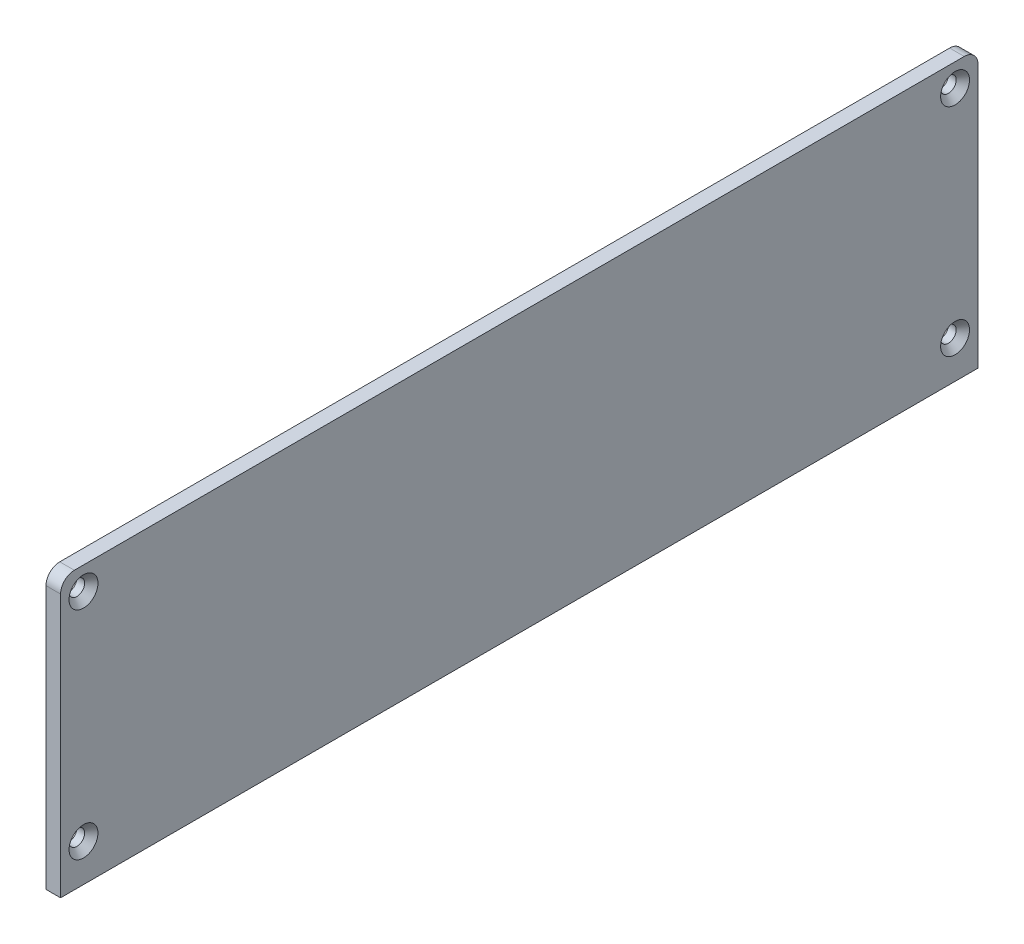
from build123d import *

# Parameters (mm, degrees)
BOSS_EXTRUDE1_DEPTH                             = 3.175
CSK_FOR_M3_FLAT_HEAD_MACHINE_SCREW1_D           = 3.4
CSK_FOR_M3_FLAT_HEAD_MACHINE_SCREW1_CSINK_D     = 6.3
CSK_FOR_M3_FLAT_HEAD_MACHINE_SCREW1_CSINK_ANGLE = 90


with BuildPart() as part:
    # Sketch1 → Boss-Extrude1 (new body)
    with BuildSketch(Plane(origin=(0, 0, 0), x_dir=(0, 0, -1), z_dir=(1, 0, 0))):
        with BuildLine():
            Line((-100, 0), (100, 0))
            Line((100, 0), (100, 57.35))
            ThreePointArc((100, 57.35), (99.121320344, 59.471320344), (97, 60.35))
            Line((97, 60.35), (-97, 60.35))
            ThreePointArc((-97, 60.35), (-99.121320344, 59.471320344), (-100, 57.35))
            Line((-100, 57.35), (-100, 0))
        make_face()
    extrude(amount=BOSS_EXTRUDE1_DEPTH)

    # CSK for M3 Flat Head Machine Screw1 (through all)
    with Locations(Plane(origin=(3.175, 0, 0), x_dir=(0, 0, -1), z_dir=(1, 0, 0))):
        with Locations((-95, 8.175), (-95, 55.35)):
            csk_for_m3_flat_head_machine_screw1 = CounterSinkHole(CSK_FOR_M3_FLAT_HEAD_MACHINE_SCREW1_D / 2, CSK_FOR_M3_FLAT_HEAD_MACHINE_SCREW1_CSINK_D / 2, counter_sink_angle=CSK_FOR_M3_FLAT_HEAD_MACHINE_SCREW1_CSINK_ANGLE)

    # Mirror1: CSK for M3 Flat Head Machine Screw1 across plane
    add(csk_for_m3_flat_head_machine_screw1.mirror(Plane.XY), mode=Mode.SUBTRACT)


solid = part.part
